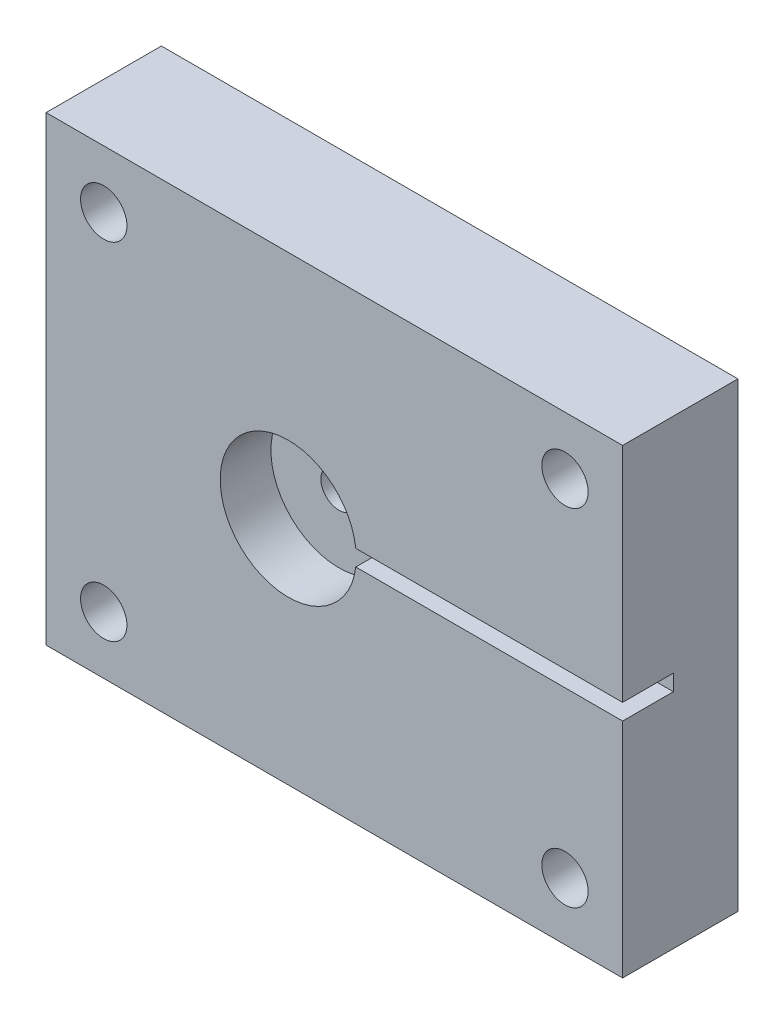
from build123d import *

# Parameters (mm, degrees)
SKETCH1_W               = 63.5
SKETCH1_H               = 50.8
BOSS_EXTRUDE1_DEPTH     = 12.7
CUT_EXTRUDE1_START      = -5.588
SKETCH2_R               = 7.493
CUT_EXTRUDE1_DEPTH      = 5.588
CUT_EXTRUDE2_START      = -5.588
SKETCH3_W               = 31.75
SKETCH3_H               = 1.778
CUT_EXTRUDE2_DEPTH      = 5.588
SKETCH9_R               = 1.9939
CUT_EXTRUDE3_DEPTH      = 11.9888
CUT_EXTRUDE4_START      = -4.572
SKETCH10_R              = 7.493
CUT_EXTRUDE4_DEPTH      = 4.572
SKETCH11_R              = 2.5527
CUT_EXTRUDE5_DEPTH      = 13.7
MIRROR2_COPY_1_SKETCH_R = 2.5527
MIRROR2_COPY_1_DEPTH    = 13.7


with BuildPart() as part:
    # Sketch1 → Boss-Extrude1 (new body)
    with BuildSketch(Plane.XY):
        Rectangle(SKETCH1_W, SKETCH1_H)
    extrude(amount=BOSS_EXTRUDE1_DEPTH)

    # Sketch2 → Cut-Extrude1 (cut)
    with BuildSketch(Plane.XY.offset(12.7).offset(CUT_EXTRUDE1_START)):
        with Locations((-5.08, 0)):
            Circle(SKETCH2_R)
    extrude(amount=CUT_EXTRUDE1_DEPTH, mode=Mode.SUBTRACT)

    # Sketch3 → Cut-Extrude2 (cut)
    with BuildSketch(Plane.XY.offset(12.7).offset(CUT_EXTRUDE2_START)):
        with Locations((15.875, 0)):
            Rectangle(SKETCH3_W, SKETCH3_H)
    extrude(amount=CUT_EXTRUDE2_DEPTH, mode=Mode.SUBTRACT)

    # Sketch9 → Cut-Extrude3 (cut)
    with BuildSketch(Plane.XY.offset(7.112)):
        with Locations((-5.08, 0)):
            Circle(SKETCH9_R)
    extrude(amount=-CUT_EXTRUDE3_DEPTH, mode=Mode.SUBTRACT)

    # Sketch10 → Cut-Extrude4 (cut)
    with BuildSketch(Plane(origin=(0, 0, 0), x_dir=(-1, 0, 0), z_dir=(0, 0, -1)).offset(CUT_EXTRUDE4_START)):
        with Locations((5.08, 0)):
            Circle(SKETCH10_R)
    extrude(amount=CUT_EXTRUDE4_DEPTH, mode=Mode.SUBTRACT)

    # Sketch11 → Cut-Extrude5 (cut, through all)
    with BuildSketch(Plane.XY.offset(12.7)):
        with Locations((-25.4, 19.05)):
            Circle(SKETCH11_R)
    cut_extrude5 = extrude(amount=-CUT_EXTRUDE5_DEPTH, mode=Mode.SUBTRACT)

    # Mirror1: Cut-Extrude5 across plane
    add(cut_extrude5.mirror(Plane(origin=(0, 0, 0), x_dir=(0, 0, 1), z_dir=(1, 0, 0))), mode=Mode.SUBTRACT)

    # Mirror2: Cut-Extrude5 across plane
    add(cut_extrude5.mirror(Plane.ZX), mode=Mode.SUBTRACT)

    # Mirror2 copy 1 sketch → Mirror2 copy 1 (cut, through all)
    with BuildSketch(Plane(origin=(0, 0, 12.7), x_dir=(-1, 0, 0), z_dir=(0, 0, 1))):
        with Locations((-25.4, 19.05)):
            Circle(MIRROR2_COPY_1_SKETCH_R)
    extrude(amount=-MIRROR2_COPY_1_DEPTH, mode=Mode.SUBTRACT)


solid = part.part
